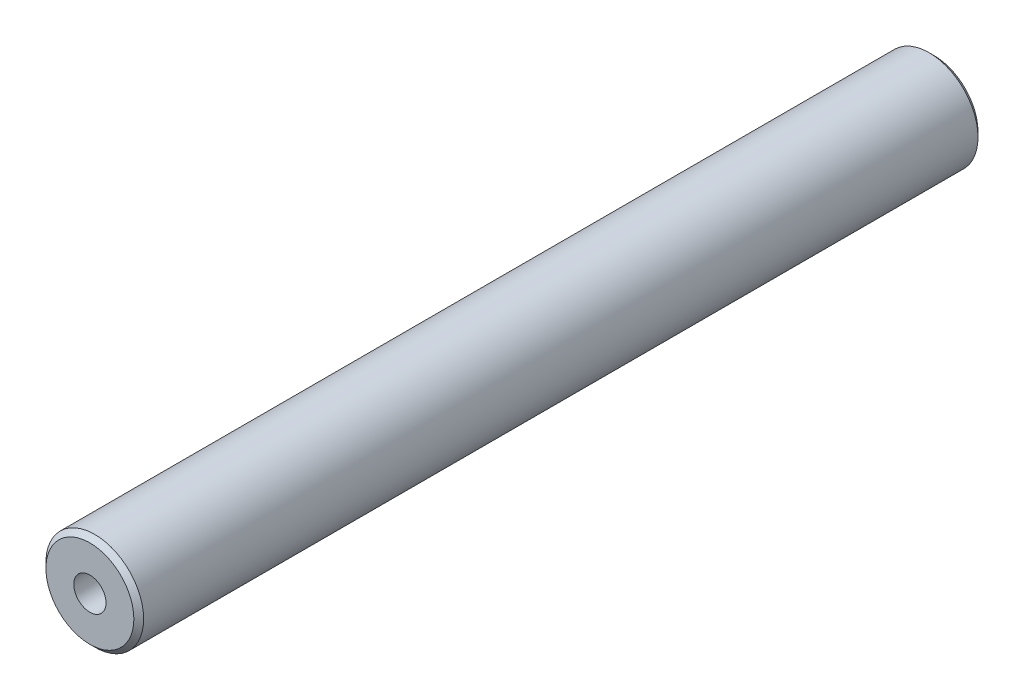
from build123d import *

# Parameters (mm, degrees)
ESQUISSE1_R               = 5
BOSS_EXTRU_1_DEPTH        = 86.4
TROU_TARAUD_M4X0_71_D     = 3.3
TROU_TARAUD_M4X0_71_DEPTH = 20
TROU_TARAUD_M4X0_71_TIP   = 0.991420021
TROU_TARAUD_M4X0_72_D     = 3.3
TROU_TARAUD_M4X0_72_DEPTH = 20
TROU_TARAUD_M4X0_72_TIP   = 0.991420021
CHANFREIN1_SIZE           = 0.5


with BuildPart() as part:
    # Esquisse1 → Boss.-Extru.1 (new body)
    with BuildSketch(Plane.XY):
        Circle(ESQUISSE1_R)
    extrude(amount=BOSS_EXTRU_1_DEPTH)

    # Trou taraudé M4x0.71
    with Locations(Plane.XY.offset(86.4)):
        with Locations((0, 0)):
            Hole(TROU_TARAUD_M4X0_71_D / 2, depth=TROU_TARAUD_M4X0_71_DEPTH)
            with Locations((0, 0, -(TROU_TARAUD_M4X0_71_DEPTH + TROU_TARAUD_M4X0_71_TIP / 2))):  # 118° drill point
                Cone(0, TROU_TARAUD_M4X0_71_D / 2, TROU_TARAUD_M4X0_71_TIP, mode=Mode.SUBTRACT)

    # Trou taraudé M4x0.72
    with Locations(Plane(origin=(0, 0, 0), x_dir=(-1, 0, 0), z_dir=(0, 0, -1))):
        with Locations((0, 0)):
            Hole(TROU_TARAUD_M4X0_72_D / 2, depth=TROU_TARAUD_M4X0_72_DEPTH)
            with Locations((0, 0, -(TROU_TARAUD_M4X0_72_DEPTH + TROU_TARAUD_M4X0_72_TIP / 2))):  # 118° drill point
                Cone(0, TROU_TARAUD_M4X0_72_D / 2, TROU_TARAUD_M4X0_72_TIP, mode=Mode.SUBTRACT)

    # Chanfrein1
    chanfrein1_edges = [part.edges().sort_by_distance(p)[0] for p in [
        (-5, 0, 0),
        (-5, 0, 86.4),
    ]]
    chamfer(chanfrein1_edges, length=CHANFREIN1_SIZE)


solid = part.part
